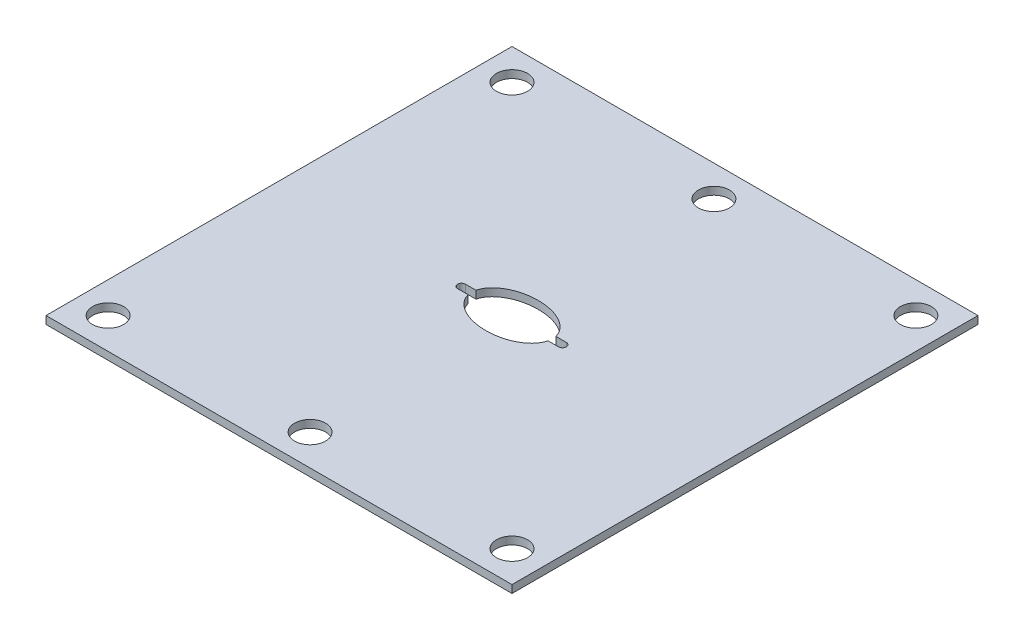
from build123d import *

# Parameters (mm, degrees)
SKETCH1_W                    = 60
SKETCH1_H                    = 60
BOSS_EXTRUDE1_DEPTH          = 1
F_4_0_4_DIAMETER_HOLE1_D     = 4
F_4_0_4_DIAMETER_HOLE1_DEPTH = 1
SKETCH3_R                    = 0.5
CUT_EXTRUDE1_DEPTH           = 5
SKETCH9_W                    = 13
SKETCH9_H                    = 1
CUT_EXTRUDE7_DEPTH           = 5
SKETCH10_RX                  = 5.193553557
SKETCH10_RY                  = 3.369235694
CUT_EXTRUDE8_DEPTH           = 5


with BuildPart() as part:
    # Sketch1 → Boss-Extrude1 (new body)
    with BuildSketch(Plane(origin=(0, 0, 0), x_dir=(1, 0, 0), z_dir=(0, 1, 0))):
        Rectangle(SKETCH1_W, SKETCH1_H)
    extrude(amount=BOSS_EXTRUDE1_DEPTH)

    # Ø4.0 (4) Diameter Hole1
    with Locations(Plane(origin=(0, 1, 0), x_dir=(1, 0, 0), z_dir=(0, 1, 0))):
        with Locations((26, 26), (0, 26), (-26, 26), (0, -26), (26, -26), (-26, -26)):
            Hole(F_4_0_4_DIAMETER_HOLE1_D / 2, depth=F_4_0_4_DIAMETER_HOLE1_DEPTH)

    # Sketch3 → Cut-Extrude1 (cut)
    with BuildSketch(Plane(origin=(0, 1, 0), x_dir=(1, 0, 0), z_dir=(0, 1, 0))):
        with Locations((6.5, 0)):
            Circle(SKETCH3_R)
        with Locations((-6.5, 0)):
            Circle(SKETCH3_R)
    extrude(amount=-CUT_EXTRUDE1_DEPTH, mode=Mode.SUBTRACT)

    # Sketch9 → Cut-Extrude7 (cut)
    with BuildSketch(Plane(origin=(0, 1, 0), x_dir=(1, 0, 0), z_dir=(0, 1, 0))):
        Rectangle(SKETCH9_W, SKETCH9_H)
    extrude(amount=-CUT_EXTRUDE7_DEPTH, mode=Mode.SUBTRACT)

    # Sketch10 → Cut-Extrude8 (cut)
    with BuildSketch(Plane(origin=(0, 1, 0), x_dir=(1, 0, 0), z_dir=(0, 1, 0))):
        with Locations(Location((0, 0), (0, 0, 180))):
            Ellipse(SKETCH10_RX, SKETCH10_RY)
    extrude(amount=-CUT_EXTRUDE8_DEPTH, mode=Mode.SUBTRACT)


solid = part.part
